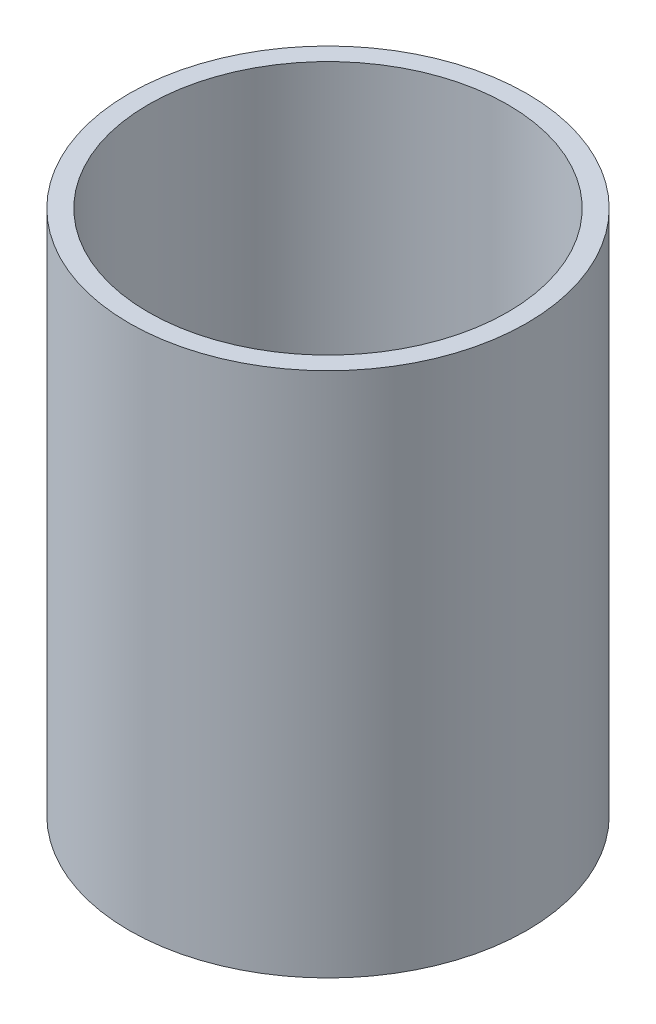
from build123d import *

# Parameters (mm, degrees)
ESQUISSE1_R        = 25
ESQUISSE1_R_2      = 22.6
BOSS_EXTRU_1_DEPTH = 33.06


with BuildPart() as part:
    # Esquisse1 → Boss.-Extru.1 (new body, symmetric)
    with BuildSketch(Plane(origin=(0, 0, 0), x_dir=(1, 0, 0), z_dir=(0, 1, 0))):
        Circle(ESQUISSE1_R)
        Circle(ESQUISSE1_R_2, mode=Mode.SUBTRACT)
    extrude(amount=BOSS_EXTRU_1_DEPTH, both=True)


solid = part.part
